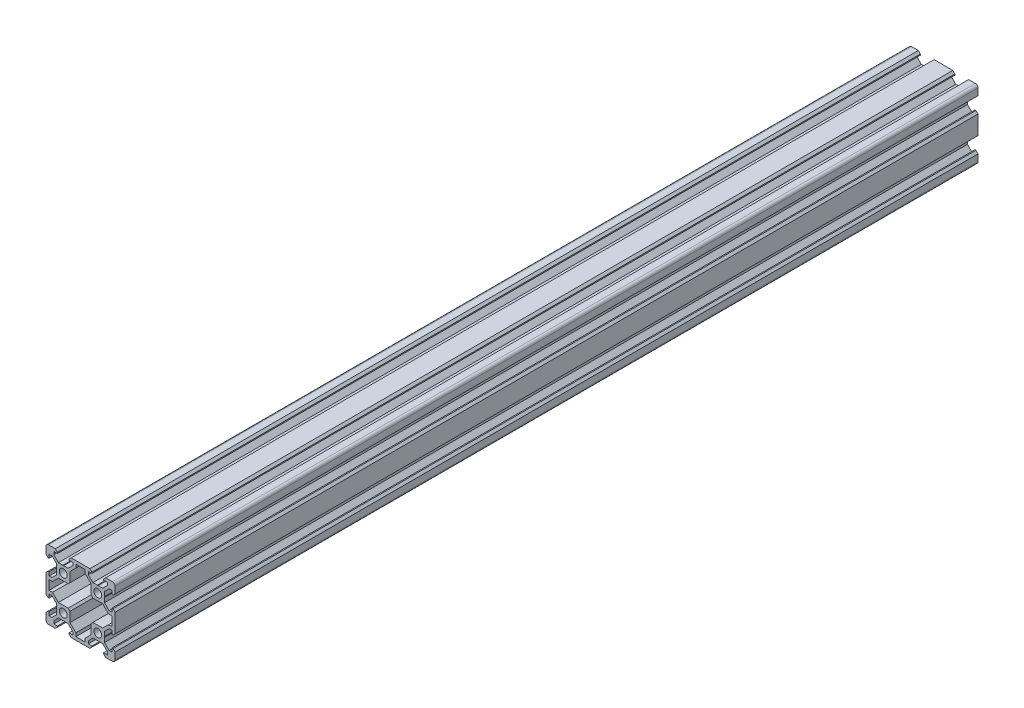
from build123d import *

# Parameters (mm, degrees)
SKETCH1_R           = 2.3
BOSS_EXTRUDE1_DEPTH = 500


with BuildPart() as part:
    # Sketch1 → Boss-Extrude1 (new body)
    with BuildSketch(Plane.XY):
        with BuildLine():
            Line((14.58, -20), (18.5, -20))
            ThreePointArc((18.5, -20), (19.560660172, -19.560660172), (20, -18.5))
            Line((20, -18.5), (20, -14.58))
            Line((20, -14.58), (18.815, -13.395))
            Line((18.815, -13.395), (18.2, -13.395))
            Line((18.2, -13.395), (18.2, -15.5))
            Line((18.2, -15.5), (16.560660172, -15.5))
            Line((16.560660172, -15.5), (13.9, -12.839339828))
            Line((13.9, -12.839339828), (13.9, -10.21))
            Line((13.9, -10.21), (13.69, -10))
            Line((13.69, -10), (13.9, -9.79))
            Line((13.9, -9.79), (13.9, -7.160660172))
            Line((13.9, -7.160660172), (16.560660172, -4.5))
            Line((16.560660172, -4.5), (18.2, -4.5))
            Line((18.2, -4.5), (18.2, -6.605))
            Line((18.2, -6.605), (18.815, -6.605))
            Line((18.815, -6.605), (20, -5.42))
            Line((20, -5.42), (20, 5.42))
            Line((20, 5.42), (18.815, 6.605))
            Line((18.815, 6.605), (18.2, 6.605))
            Line((18.2, 6.605), (18.2, 4.5))
            Line((18.2, 4.5), (16.560660172, 4.5))
            Line((16.560660172, 4.5), (13.9, 7.160660172))
            Line((13.9, 7.160660172), (13.9, 9.79))
            Line((13.9, 9.79), (13.69, 10))
            Line((13.69, 10), (13.9, 10.21))
            Line((13.9, 10.21), (13.9, 12.839339828))
            Line((13.9, 12.839339828), (16.560660172, 15.5))
            Line((16.560660172, 15.5), (18.2, 15.5))
            Line((18.2, 15.5), (18.2, 13.395))
            Line((18.2, 13.395), (18.815, 13.395))
            Line((18.815, 13.395), (20, 14.58))
            Line((20, 14.58), (20, 18.5))
            ThreePointArc((20, 18.5), (19.560660172, 19.560660172), (18.5, 20))
            Line((18.5, 20), (14.58, 20))
            Line((14.58, 20), (13.395, 18.815))
            Line((13.395, 18.815), (13.395, 18.2))
            Line((13.395, 18.2), (15.5, 18.2))
            Line((15.5, 18.2), (15.5, 16.560660172))
            Line((15.5, 16.560660172), (12.839339828, 13.9))
            Line((12.839339828, 13.9), (10.21, 13.9))
            Line((10.21, 13.9), (10, 13.69))
            Line((10, 13.69), (9.79, 13.9))
            Line((9.79, 13.9), (7.160660172, 13.9))
            Line((7.160660172, 13.9), (4.5, 16.560660172))
            Line((4.5, 16.560660172), (4.5, 18.2))
            Line((4.5, 18.2), (6.605, 18.2))
            Line((6.605, 18.2), (6.605, 18.815))
            Line((6.605, 18.815), (5.42, 20))
            Line((5.42, 20), (-5.42, 20))
            Line((-5.42, 20), (-6.605, 18.815))
            Line((-6.605, 18.815), (-6.605, 18.2))
            Line((-6.605, 18.2), (-4.5, 18.2))
            Line((-4.5, 18.2), (-4.5, 16.560660172))
            Line((-4.5, 16.560660172), (-7.160660172, 13.9))
            Line((-7.160660172, 13.9), (-9.79, 13.9))
            Line((-9.79, 13.9), (-10, 13.69))
            Line((-10, 13.69), (-10.21, 13.9))
            Line((-10.21, 13.9), (-12.839339828, 13.9))
            Line((-12.839339828, 13.9), (-15.5, 16.560660172))
            Line((-15.5, 16.560660172), (-15.5, 18.2))
            Line((-15.5, 18.2), (-13.395, 18.2))
            Line((-13.395, 18.2), (-13.395, 18.815))
            Line((-13.395, 18.815), (-14.58, 20))
            Line((-14.58, 20), (-18.5, 20))
            ThreePointArc((-18.5, 20), (-19.560660172, 19.560660172), (-20, 18.5))
            Line((-20, 18.5), (-20, 14.58))
            Line((-20, 14.58), (-18.815, 13.395))
            Line((-18.815, 13.395), (-18.2, 13.395))
            Line((-18.2, 13.395), (-18.2, 15.5))
            Line((-18.2, 15.5), (-16.560660172, 15.5))
            Line((-16.560660172, 15.5), (-13.9, 12.839339828))
            Line((-13.9, 12.839339828), (-13.9, 10.21))
            Line((-13.9, 10.21), (-13.69, 10))
            Line((-13.69, 10), (-13.9, 9.79))
            Line((-13.9, 9.79), (-13.9, 7.160660172))
            Line((-13.9, 7.160660172), (-16.560660172, 4.5))
            Line((-16.560660172, 4.5), (-18.2, 4.5))
            Line((-18.2, 4.5), (-18.2, 6.605))
            Line((-18.2, 6.605), (-18.815, 6.605))
            Line((-18.815, 6.605), (-20, 5.42))
            Line((-20, 5.42), (-20, -5.42))
            Line((-20, -5.42), (-18.815, -6.605))
            Line((-18.815, -6.605), (-18.2, -6.605))
            Line((-18.2, -6.605), (-18.2, -4.5))
            Line((-18.2, -4.5), (-16.560660172, -4.5))
            Line((-16.560660172, -4.5), (-13.9, -7.160660172))
            Line((-13.9, -7.160660172), (-13.9, -9.79))
            Line((-13.9, -9.79), (-13.69, -10))
            Line((-13.69, -10), (-13.9, -10.21))
            Line((-13.9, -10.21), (-13.9, -12.839339828))
            Line((-13.9, -12.839339828), (-16.560660172, -15.5))
            Line((-16.560660172, -15.5), (-18.2, -15.5))
            Line((-18.2, -15.5), (-18.2, -13.395))
            Line((-18.2, -13.395), (-18.815, -13.395))
            Line((-18.815, -13.395), (-20, -14.58))
            Line((-20, -14.58), (-20, -18.5))
            ThreePointArc((-20, -18.5), (-19.560660172, -19.560660172), (-18.5, -20))
            Line((-18.5, -20), (-14.58, -20))
            Line((-14.58, -20), (-13.395, -18.815))
            Line((-13.395, -18.815), (-13.395, -18.2))
            Line((-13.395, -18.2), (-15.5, -18.2))
            Line((-15.5, -18.2), (-15.5, -16.560660172))
            Line((-15.5, -16.560660172), (-12.839339828, -13.9))
            Line((-12.839339828, -13.9), (-10.21, -13.9))
            Line((-10.21, -13.9), (-10, -13.69))
            Line((-10, -13.69), (-9.79, -13.9))
            Line((-9.79, -13.9), (-7.160660172, -13.9))
            Line((-7.160660172, -13.9), (-4.5, -16.560660172))
            Line((-4.5, -16.560660172), (-4.5, -18.2))
            Line((-4.5, -18.2), (-6.605, -18.2))
            Line((-6.605, -18.2), (-6.605, -18.815))
            Line((-6.605, -18.815), (-5.42, -20))
            Line((-5.42, -20), (5.42, -20))
            Line((5.42, -20), (6.605, -18.815))
            Line((6.605, -18.815), (6.605, -18.2))
            Line((6.605, -18.2), (4.5, -18.2))
            Line((4.5, -18.2), (4.5, -16.560660172))
            Line((4.5, -16.560660172), (7.160660172, -13.9))
            Line((7.160660172, -13.9), (9.79, -13.9))
            Line((9.79, -13.9), (10, -13.69))
            Line((10, -13.69), (10.21, -13.9))
            Line((10.21, -13.9), (12.839339828, -13.9))
            Line((12.839339828, -13.9), (15.5, -16.560660172))
            Line((15.5, -16.560660172), (15.5, -18.2))
            Line((15.5, -18.2), (13.395, -18.2))
            Line((13.395, -18.2), (13.395, -18.815))
            Line((13.395, -18.815), (14.58, -20))
        make_face()
        with Locations((-10, -10)):
            Circle(SKETCH1_R, mode=Mode.SUBTRACT)
        with Locations((10, -10)):
            Circle(SKETCH1_R, mode=Mode.SUBTRACT)
        Polygon((-16.239339828, -2.7), (-18.2, -2.7), (-18.2, 2.7), (-16.239339828, 2.7), (-12.839339828, 6.1), (-7.160660172, 6.1), (-6.1, 7.160660172), (-6.1, 12.839339828), (-2.7, 16.239339828), (-2.7, 18.2), (2.7, 18.2), (2.7, 16.239339828), (6.1, 12.839339828), (6.1, 7.160660172), (7.160660172, 6.1), (12.839339828, 6.1), (16.239339828, 2.7), (18.2, 2.7), (18.2, -2.7), (16.239339828, -2.7), (12.839339828, -6.1), (7.160660172, -6.1), (6.1, -7.160660172), (6.1, -12.839339828), (2.7, -16.239339828), (2.7, -18.2), (-2.7, -18.2), (-2.7, -16.239339828), (-6.1, -12.839339828), (-6.1, -7.160660172), (-7.160660172, -6.1), (-12.839339828, -6.1), align=None, mode=Mode.SUBTRACT)
        with Locations((-10, 10)):
            Circle(SKETCH1_R, mode=Mode.SUBTRACT)
        with Locations((10, 10)):
            Circle(SKETCH1_R, mode=Mode.SUBTRACT)
    extrude(amount=BOSS_EXTRUDE1_DEPTH)


solid = part.part
